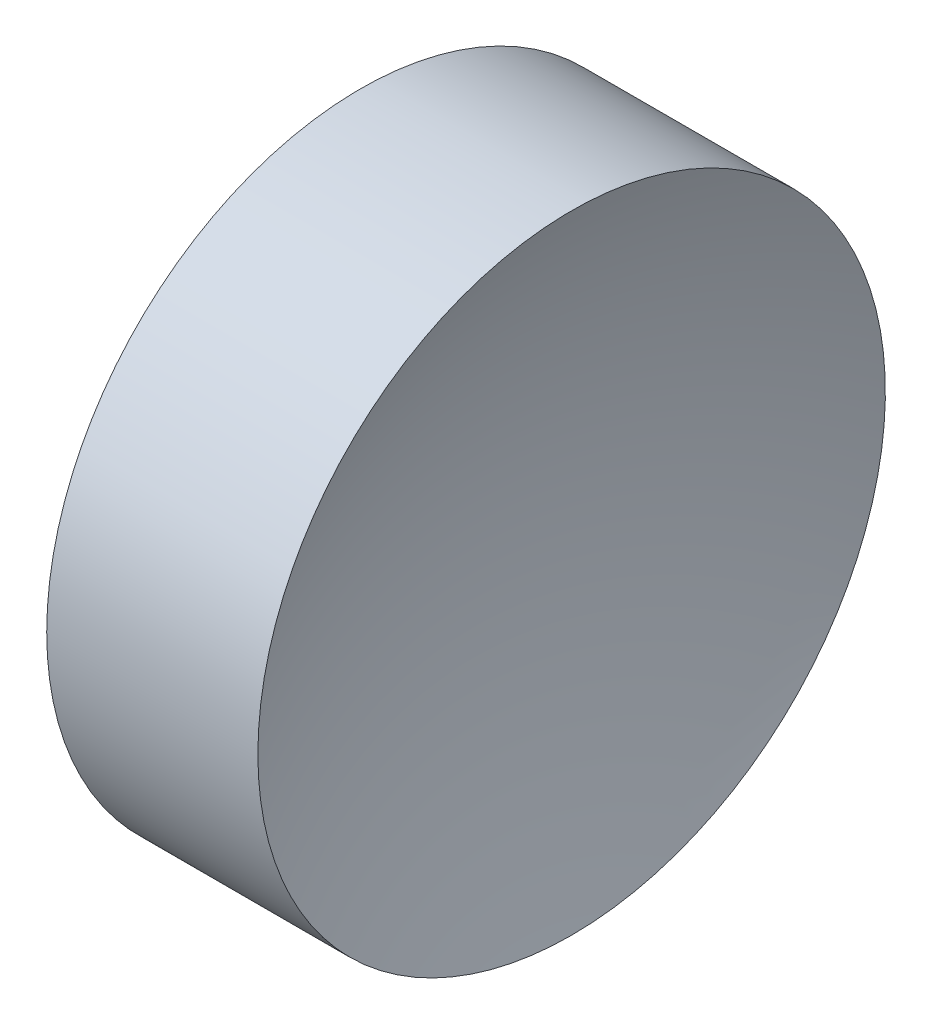
from build123d import *


with BuildPart() as part:
    # 草图1 → 旋转1 (revolve)
    with BuildSketch(Plane.XY, mode=Mode.PRIVATE) as revolve_1_sk:
        with BuildLine():
            Line((22.172189475, 13.044520575), (22.172189475, 16.194520575))
            Line((22.172189475, 16.194520575), (24.292189475, 16.194520575))
            ThreePointArc((24.292189475, 16.194520575), (23.828662526, 14.649738595), (23.672189825, 13.044520575))
            Line((23.672189825, 13.044520575), (22.172189475, 13.044520575))
        make_face()
    revolve(revolve_1_sk.sketch.rotate(Axis((21.224930557, 13.044520575, 0), (1, 0, 0)), 180), axis=Axis((21.224930557, 13.044520575, 0), (1, 0, 0)))  # turned: the seam where the file's is


solid = part.part
